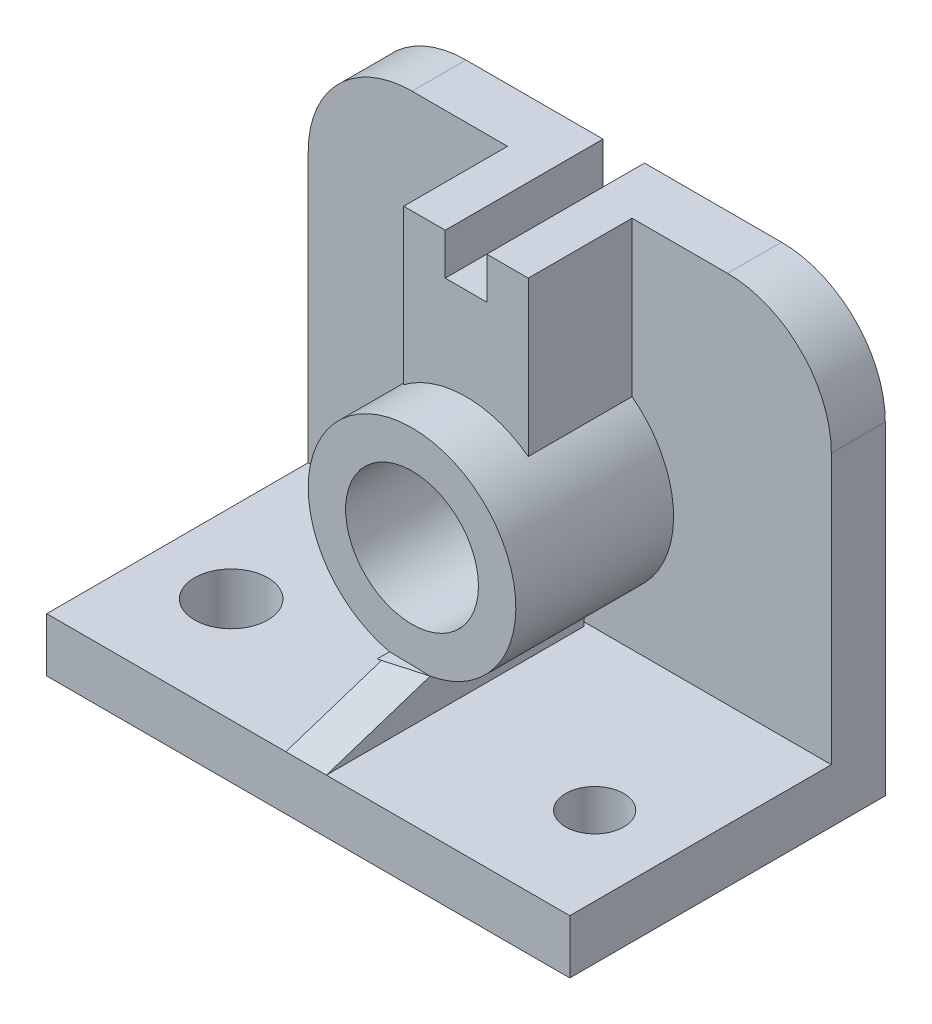
from build123d import *

# Parameters (mm, degrees)
SKETCH1_W            = 126
SKETCH1_H            = 76
BOSS_EXTRUDE1_DEPTH  = 13
SKETCH2_W            = 126
SKETCH2_H            = 90
BOSS_EXTRUDE2_DEPTH  = 13
FILLET1_R            = 25
SKETCH3_W            = 10
SKETCH3_H            = 25.459891015
BOSS_EXTRUDE3_DEPTH  = 10
SKETCH4_W            = 10
SKETCH4_H            = 13
CUT_EXTRUDE1_DEPTH   = 10
SKETCH8_R            = 25
BOSS_EXTRUDE4_DEPTH  = 38
SKETCH10_R           = 16
CUT_EXTRUDE3_DEPTH   = 38
BOSS_EXTRUDE8_DEPTH  = 25
SKETCH12_W           = 10
SKETCH12_H           = 10
CUT_EXTRUDE4_DEPTH   = 45
SKETCH13_R           = 8.829907476
CUT_EXTRUDE5_DEPTH   = 14
SKETCH14_R           = 7
CUT_EXTRUDE6_DEPTH   = 34
BOSS_EXTRUDE11_DEPTH = 37
CUT_EXTRUDE7_DEPTH   = 37


with BuildPart() as part:
    # Sketch1 → Boss-Extrude1 (new body)
    with BuildSketch(Plane(origin=(0, 0, 0), x_dir=(1, 0, 0), z_dir=(0, 1, 0))):
        with Locations((9.064748201, -38.597122302)):
            Rectangle(SKETCH1_W, SKETCH1_H)
    extrude(amount=BOSS_EXTRUDE1_DEPTH)

    # Sketch2 → Boss-Extrude2 (add)
    with BuildSketch(Plane(origin=(0, 0, 0.597122302), x_dir=(-1, 0, 0), z_dir=(0, 0, -1))):
        with Locations((-9.064748201, 58)):
            Rectangle(SKETCH2_W, SKETCH2_H)
    extrude(amount=-BOSS_EXTRUDE2_DEPTH)

    # Fillet1
    fillet1_edges = [part.edges().sort_by_distance(p)[0] for p in [
        (72.064748201, 103, 7.097122302),
        (-53.935251799, 103, 7.097122302),
    ]]
    fillet(fillet1_edges, radius=FILLET1_R)

    # Sketch3 → Boss-Extrude3 (add)
    with BuildSketch(Plane(origin=(0, 103, 0), x_dir=(1, 0, 0), z_dir=(0, 1, 0))):
        with Locations((9.064748201, -26.32706781)):
            Rectangle(SKETCH3_W, SKETCH3_H)
    extrude(amount=-BOSS_EXTRUDE3_DEPTH)

    # Sketch4 → Cut-Extrude1 (cut)
    with BuildSketch(Plane(origin=(0, 103, 0), x_dir=(1, 0, 0), z_dir=(0, 1, 0))):
        with Locations((9.064748201, -7.097122302)):
            Rectangle(SKETCH4_W, SKETCH4_H)
    extrude(amount=-CUT_EXTRUDE1_DEPTH, mode=Mode.SUBTRACT)

    # Sketch8 → Boss-Extrude4 (add)
    with BuildSketch(Plane.XY.offset(13.597122302)):
        with Locations((9.064748201, 45.775653821)):
            Circle(SKETCH8_R)
    extrude(amount=BOSS_EXTRUDE4_DEPTH)

    # Sketch10 → Cut-Extrude3 (cut)
    with BuildSketch(Plane.XY.offset(51.597122302)):
        with Locations((9.064748201, 45.775653821)):
            Circle(SKETCH10_R)
    extrude(amount=-CUT_EXTRUDE3_DEPTH, mode=Mode.SUBTRACT)

    # Sketch11 → Boss-Extrude8 (add)
    with BuildSketch(Plane.XY.offset(13.597122302)):
        with BuildLine():
            Line((4.064748201, 103), (-5.935251799, 103))
            Line((-5.935251799, 103), (-5.935251799, 65.775653821))
            ThreePointArc((-5.935251799, 65.775653821), (9.064748201, 70.775653821), (24.064748201, 65.775653821))
            Line((24.064748201, 65.775653821), (24.064748201, 103))
            Line((24.064748201, 103), (14.064748201, 103))
            Line((14.064748201, 103), (14.064748201, 93))
            Line((14.064748201, 93), (4.064748201, 93))
            Line((4.064748201, 93), (4.064748201, 103))
        make_face()
    extrude(amount=BOSS_EXTRUDE8_DEPTH)

    # Sketch12 → Cut-Extrude4 (cut)
    with BuildSketch(Plane.XY.offset(39.057013317)):
        with Locations((9.064748201, 98)):
            Rectangle(SKETCH12_W, SKETCH12_H)
    extrude(amount=-CUT_EXTRUDE4_DEPTH, mode=Mode.SUBTRACT)

    # Sketch13 → Cut-Extrude5 (cut)
    with BuildSketch(Plane(origin=(0, 13, 0), x_dir=(1, 0, 0), z_dir=(0, 1, 0))):
        with Locations((-34.808854568, -51.290114298)):
            Circle(SKETCH13_R)
    extrude(amount=-CUT_EXTRUDE5_DEPTH, mode=Mode.SUBTRACT)

    # Sketch14 → Cut-Extrude6 (cut)
    with BuildSketch(Plane(origin=(0, 13, 0), x_dir=(1, 0, 0), z_dir=(0, 1, 0))):
        with Locations((53.064748201, -51.597122302)):
            Circle(SKETCH14_R)
    extrude(amount=-CUT_EXTRUDE6_DEPTH, mode=Mode.SUBTRACT)

    # Sketch17 → Boss-Extrude11 (add, symmetric)
    with BuildSketch(Plane.XY.offset(51.597122302)):
        Polygon((3.660374399, 21.366787731), (13.431056495, 21.159899681), (13.431056495, 13), (3.660374399, 13), align=None)
    extrude(amount=BOSS_EXTRUDE11_DEPTH, both=True)

    # Sketch18 → Cut-Extrude7 (cut, symmetric)
    with BuildSketch(Plane(origin=(13.431056495, 0, 0), x_dir=(0, 0, -1), z_dir=(1, 0, 0))):
        Polygon((-51.597122302, 21.159899681), (-76.597122302, 13), (-88.597122302, 13), (-88.597122302, 23.683887041), align=None)
    extrude(amount=CUT_EXTRUDE7_DEPTH, both=True, mode=Mode.SUBTRACT)


solid = part.part
